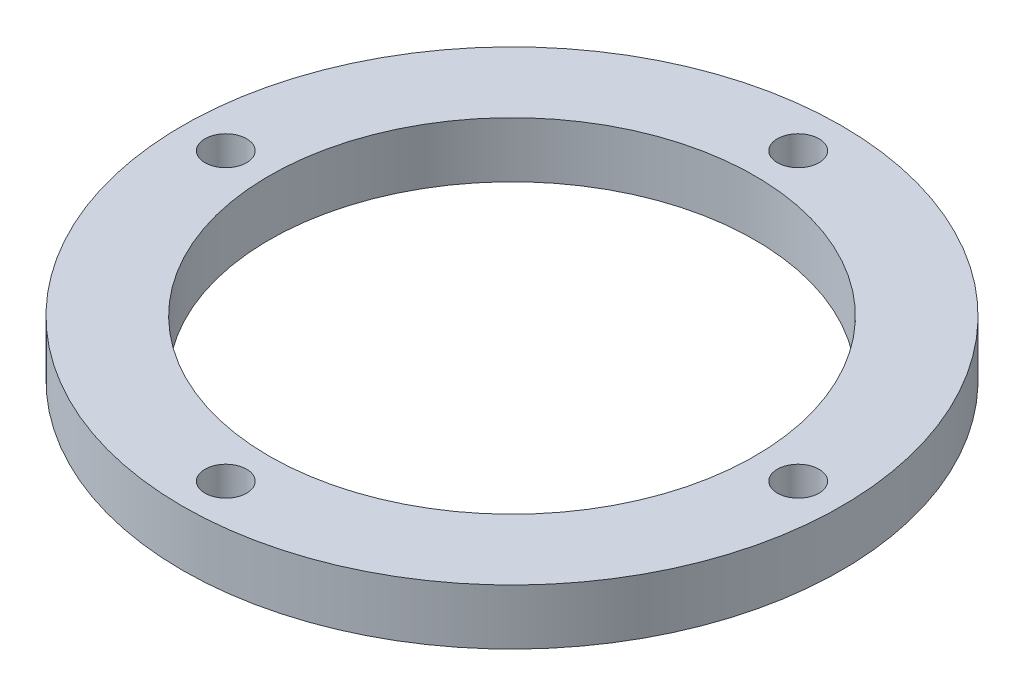
from build123d import *

# Parameters (mm, degrees)
SKETCH_1_R      = 47.5
SKETCH_1_R_2    = 35
SKETCH_1_R_3    = 3
EXTRUDE_1_DEPTH = 8


with BuildPart() as part:
    # 草图1 → 凸台-拉伸1 (new body)
    with BuildSketch(Plane(origin=(0, 0, 0), x_dir=(1, 0, 0), z_dir=(0, 1, 0))):
        Circle(SKETCH_1_R)
        Circle(SKETCH_1_R_2, mode=Mode.SUBTRACT)
        with Locations((41.25, 0)):
            Circle(SKETCH_1_R_3, mode=Mode.SUBTRACT)
        with Locations((0, -41.25)):
            Circle(SKETCH_1_R_3, mode=Mode.SUBTRACT)
        with Locations((-41.25, 0)):
            Circle(SKETCH_1_R_3, mode=Mode.SUBTRACT)
        with Locations((0, 41.25)):
            Circle(SKETCH_1_R_3, mode=Mode.SUBTRACT)
    extrude(amount=EXTRUDE_1_DEPTH)


solid = part.part
